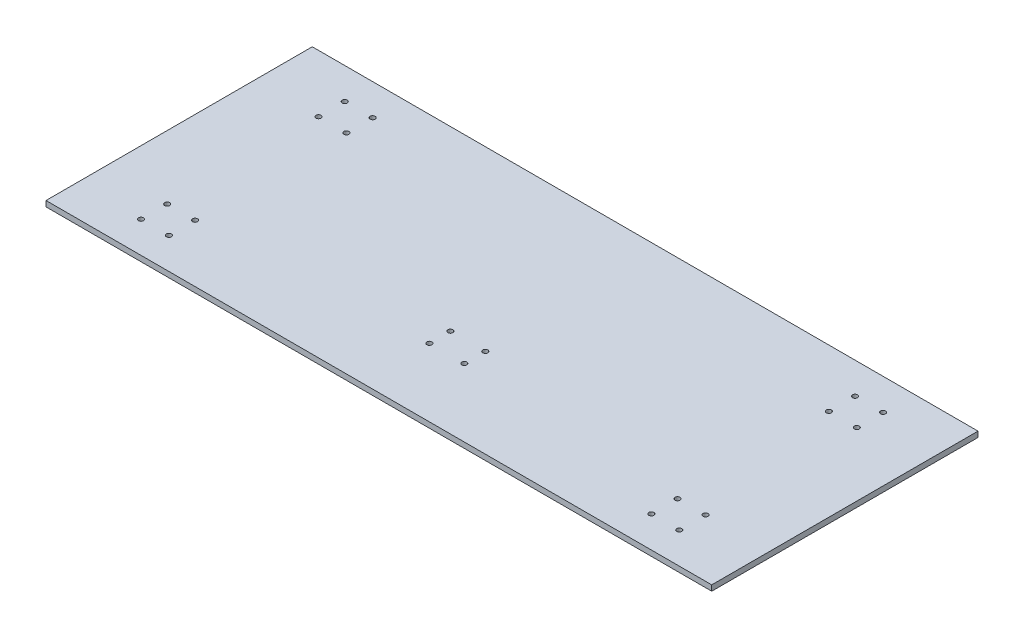
from build123d import *

# Parameters (mm, degrees)
SKETCH1_W                = 762
SKETCH1_H                = 304.8
BOSS_EXTRUDE1_DEPTH      = 6.35
M5_CLEARANCE_HOLE1_D     = 5.8
M5_CLEARANCE_HOLE1_DEPTH = 6.35


with BuildPart() as part:
    # Sketch1 → Boss-Extrude1 (new body)
    with BuildSketch(Plane(origin=(0, 0, 0), x_dir=(1, 0, 0), z_dir=(0, 1, 0))):
        Rectangle(SKETCH1_W, SKETCH1_H)
    extrude(amount=BOSS_EXTRUDE1_DEPTH)

    # M5 Clearance Hole1
    with Locations(Plane(origin=(0, 6.35, 0), x_dir=(1, 0, 0), z_dir=(0, 1, 0))):
        with Locations((276.100000001, 116.6), (276.100000001, 86.6), (308.100000001, 116.6), (308.100000001, 86.6), (276.100000001, -86.6), (276.100000001, -116.6), (308.100000001, -86.6), (308.100000001, -116.6), (-308.100000001, 116.6), (-308.100000001, 86.6), (-276.100000001, 116.6), (-276.100000001, 86.6), (-276.100000001, -86.6), (-276.100000001, -116.6), (-308.100000001, -116.6), (-308.100000001, -86.6), (20.000000025, -50.55), (20.000000025, -74.55), (-19.999999975, -74.55), (-19.999999975, -50.55)):
            Hole(M5_CLEARANCE_HOLE1_D / 2, depth=M5_CLEARANCE_HOLE1_DEPTH)


solid = part.part
